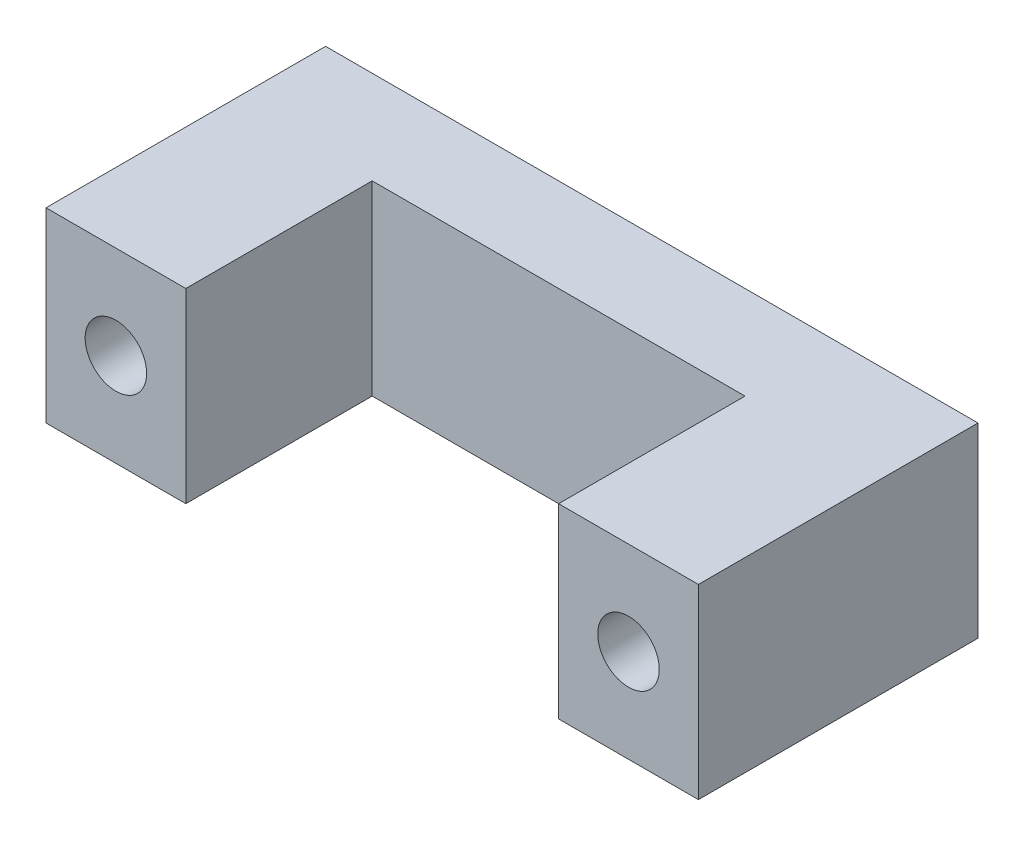
from build123d import *

# Parameters (mm, degrees)
SKETCH1_W           = 35
SKETCH1_H           = 10
SKETCH1_R           = 1.65
BOSS_EXTRUDE1_DEPTH = 15
SKETCH2_W           = 20
SKETCH2_H           = 10
CUT_EXTRUDE1_DEPTH  = 10


with BuildPart() as part:
    # Sketch1 → Boss-Extrude1 (new body)
    with BuildSketch(Plane.XY):
        Rectangle(SKETCH1_W, SKETCH1_H)
        with Locations((-13.75, 0)):
            Circle(SKETCH1_R, mode=Mode.SUBTRACT)
        with Locations((13.75, 0)):
            Circle(SKETCH1_R, mode=Mode.SUBTRACT)
    extrude(amount=BOSS_EXTRUDE1_DEPTH)

    # Sketch2 → Cut-Extrude1 (cut)
    with BuildSketch(Plane.XY.offset(15)):
        Rectangle(SKETCH2_W, SKETCH2_H)
    extrude(amount=-CUT_EXTRUDE1_DEPTH, mode=Mode.SUBTRACT)


solid = part.part
